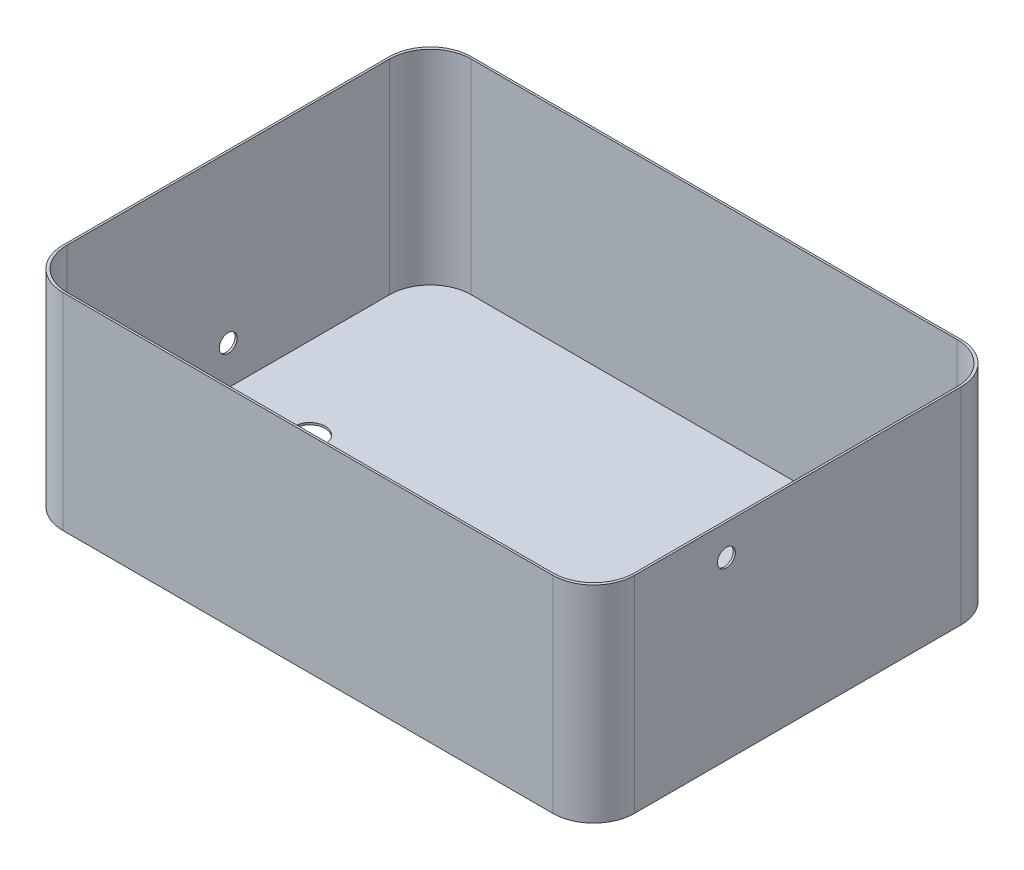
from build123d import *

# Parameters (mm, degrees)
SKETCH1_W                        = 711.2
SKETCH1_H                        = 508
SKETCH1_W_2                      = 706.12
SKETCH1_H_2                      = 502.92
BOSS_EXTRUDE1_DEPTH              = 254
SKETCH2_W                        = 711.2
SKETCH2_H                        = 508
BOSS_EXTRUDE2_DEPTH              = 2.54
FILLET1_R                        = 50.8
SKETCH5_R                        = 19.05
CUT_EXTRUDE1_DEPTH               = 2.54
F_7_8_0_875_DIAMETER_HOLE1_D     = 22.225
F_7_8_0_875_DIAMETER_HOLE1_DEPTH = 2.54
F_7_8_0_875_DIAMETER_HOLE2_D     = 22.225
F_7_8_0_875_DIAMETER_HOLE2_DEPTH = 2.54


with BuildPart() as part:
    # Sketch1 → Boss-Extrude1 (new body)
    with BuildSketch(Plane(origin=(0, 0, 0), x_dir=(1, 0, 0), z_dir=(0, 1, 0))):
        Rectangle(SKETCH1_W, SKETCH1_H)
        Rectangle(SKETCH1_W_2, SKETCH1_H_2, mode=Mode.SUBTRACT)
    extrude(amount=BOSS_EXTRUDE1_DEPTH)

    # Sketch2 → Boss-Extrude2 (add)
    with BuildSketch(Plane.XZ):
        Rectangle(SKETCH2_W, SKETCH2_H)
    extrude(amount=BOSS_EXTRUDE2_DEPTH)

    # Fillet1
    fillet1_edges = [part.edges().sort_by_distance(p)[0] for p in [
        (353.06, 127, 251.46),
        (353.06, 127, -251.46),
        (-353.06, 127, -251.46),
        (-353.06, 127, 251.46),
        (355.6, 125.73, 254),
        (-355.6, 125.73, 254),
        (-355.6, 125.73, -254),
        (355.6, 125.73, -254),
    ]]
    fillet(fillet1_edges, radius=FILLET1_R)

    # Sketch5 → Cut-Extrude1 (cut)
    with BuildSketch(Plane(origin=(0, 0, 0), x_dir=(1, 0, 0), z_dir=(0, 1, 0))):
        with Locations((-251.46, 0)):
            Circle(SKETCH5_R)
    extrude(amount=-CUT_EXTRUDE1_DEPTH, mode=Mode.SUBTRACT)

    # 7/8 (0.875) Diameter Hole1
    with Locations(Plane.ZY.offset(355.6)):
        with Locations((0, 48.26)):
            Hole(F_7_8_0_875_DIAMETER_HOLE1_D / 2, depth=F_7_8_0_875_DIAMETER_HOLE1_DEPTH)

    # 7/8 (0.875) Diameter Hole2
    with Locations(Plane(origin=(355.6, 0, 0), x_dir=(0, 0, -1), z_dir=(1, 0, 0))):
        with Locations((-88.9, 215.9)):
            Hole(F_7_8_0_875_DIAMETER_HOLE2_D / 2, depth=F_7_8_0_875_DIAMETER_HOLE2_DEPTH)


solid = part.part
